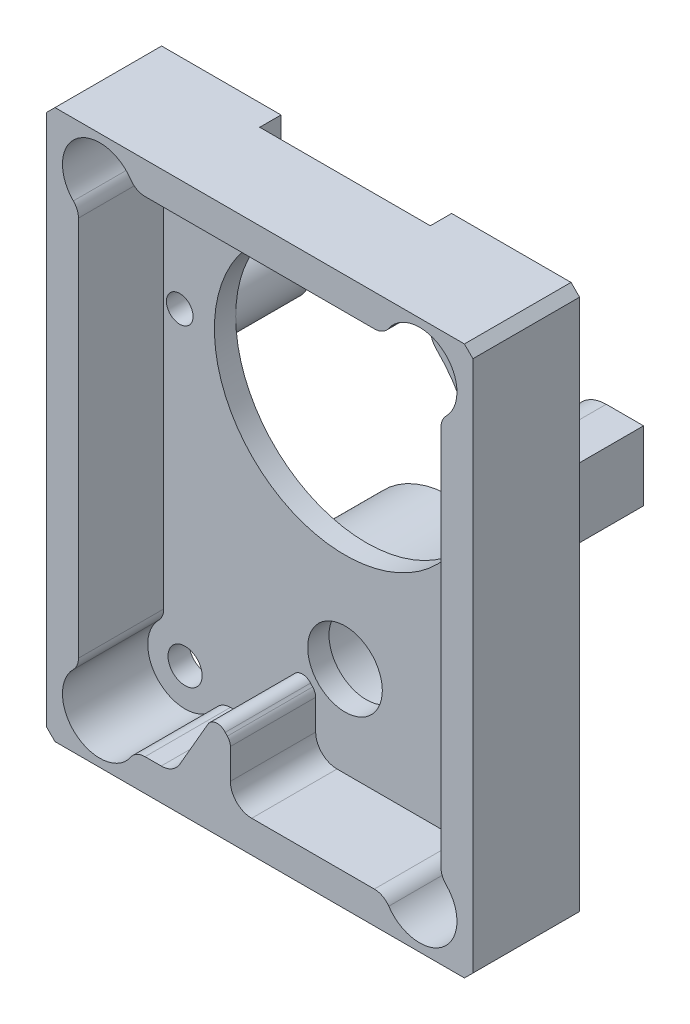
from build123d import *

# Parameters (mm, degrees)
SKETCH1_W             = 40
SKETCH1_H             = 51.5
BOSS_EXTRUDE1_DEPTH   = 18
SKETCH3_R             = 1.6
CUT_EXTRUDE1_DEPTH    = 19
SKETCH4_R             = 3.5
CUT_EXTRUDE2_DEPTH    = 18
CUT_EXTRUDE3_DEPTH    = 8
SKETCH6_R             = 9
CUT_EXTRUDE4_DEPTH    = 8
SKETCH7_R             = 7
CUT_EXTRUDE5_DEPTH    = 2.8
SKETCH8_R             = 6
CUT_EXTRUDE6_DEPTH    = 3.8
SKETCH9_R             = 5
CUT_EXTRUDE7_DEPTH    = 8
M3X0_5_TAPPED_HOLE1_D = 2.5
CUT_EXTRUDE8_DEPTH    = 2
CUT_EXTRUDE9_DEPTH    = 1
CHAMFER1_SIZE         = 0.8
SKETCH14_W            = 1
SKETCH14_H            = 6.5
CUT_EXTRUDE10_DEPTH   = 7


with BuildPart() as part:
    # Sketch1 → Boss-Extrude1 (new body)
    with BuildSketch(Plane.XY):
        Rectangle(SKETCH1_W, SKETCH1_H)
    extrude(amount=BOSS_EXTRUDE1_DEPTH)

    # Sketch3 → Cut-Extrude1 (cut, through all)
    with BuildSketch(Plane.XY.offset(18)):
        with Locations((-15, 21.5)):
            Circle(SKETCH3_R)
        with Locations((-15, -21.5)):
            Circle(SKETCH3_R)
        with Locations((15, 21.5)):
            Circle(SKETCH3_R)
        with Locations((15, -21.5)):
            Circle(SKETCH3_R)
    extrude(amount=-CUT_EXTRUDE1_DEPTH, mode=Mode.SUBTRACT)

    # Sketch4 → Cut-Extrude2 (cut)
    with BuildSketch(Plane.XY.offset(18)):
        with Locations((0, -14.25)):
            Circle(SKETCH4_R)
    extrude(amount=-CUT_EXTRUDE2_DEPTH, mode=Mode.SUBTRACT)

    # Sketch5 → Cut-Extrude3 (cut)
    with BuildSketch(Plane.XY.offset(18)):
        with BuildLine():
            Line((-17, 17.872848693), (-17, -17.872848693))
            ThreePointArc((-17, -17.872848693), (-17.124132538, -18.49783351), (-17.477686074, -19.027941805))
            ThreePointArc((-17.477686074, -19.027941805), (-17.229095042, -24.198357888), (-12.104699799, -23.466529111))
            ThreePointArc((-12.104699799, -23.466529111), (-11.517289712, -22.940191537), (-10.751842764, -22.75))
            Line((-10.751842764, -22.75), (-9.2376, -22.75))
            ThreePointArc((-9.2376, -22.75), (-8.237593216, -22.482046891), (-7.50554136, -21.749986433))
            Line((-7.50554136, -21.749986433), (-4.85642932, -17.161506784))
            ThreePointArc((-4.85642932, -17.161506784), (-4.082002001, -16.665704301), (-3.230119897, -17.011904614))
            ThreePointArc((-3.230119897, -17.011904614), (-3.134851007, -17.11961684), (-3.035950666, -17.224004614))
            ThreePointArc((-3.035950666, -17.224004614), (-2.824243732, -17.545979208), (-2.75, -17.9241))
            Line((-2.75, -17.9241), (-2.75, -20.75))
            ThreePointArc((-2.75, -20.75), (-2.164213562, -22.164213562), (-0.75, -22.75))
            Line((-0.75, -22.75), (10.751842764, -22.75))
            ThreePointArc((10.751842764, -22.75), (11.517289712, -22.940191537), (12.104699799, -23.466529111))
            ThreePointArc((12.104699799, -23.466529111), (17.229095042, -24.198357888), (17.477686074, -19.027941805))
            ThreePointArc((17.477686074, -19.027941805), (17.124132538, -18.49783351), (17, -17.872848693))
            Line((17, -17.872848693), (17, 17.872848693))
            ThreePointArc((17, 17.872848693), (17.124132538, 18.49783351), (17.477686074, 19.027941805))
            ThreePointArc((17.477686074, 19.027941805), (17.229095042, 24.198357888), (12.104699799, 23.466529111))
            ThreePointArc((12.104699799, 23.466529111), (11.517289712, 22.940191537), (10.751842764, 22.75))
            Line((10.751842764, 22.75), (-10.751842764, 22.75))
            ThreePointArc((-10.751842764, 22.75), (-11.517289712, 22.940191537), (-12.104699799, 23.466529111))
            ThreePointArc((-12.104699799, 23.466529111), (-17.229095042, 24.198357888), (-17.477686074, 19.027941805))
            ThreePointArc((-17.477686074, 19.027941805), (-17.124132538, 18.49783351), (-17, 17.872848693))
        make_face()
    extrude(amount=-CUT_EXTRUDE3_DEPTH, mode=Mode.SUBTRACT)

    # Sketch6 → Cut-Extrude4 (cut)
    with BuildSketch(Plane(origin=(0, 0, 0), x_dir=(-1, 0, 0), z_dir=(0, 0, -1))):
        with BuildLine():
            Line((-20, 10.5), (-15.5, 10.5))
            ThreePointArc((-15.5, 10.5), (-12.25, 7.25), (-15.5, 4))
            Line((-15.5, 4), (-20, 4))
            Line((-20, 4), (-20, -25.75))
            Line((-20, -25.75), (20, -25.75))
            Line((20, -25.75), (20, 4))
            Line((20, 4), (15.5, 4))
            ThreePointArc((15.5, 4), (12.25, 7.25), (15.5, 10.5))
            Line((15.5, 10.5), (20, 10.5))
            Line((20, 10.5), (20, 25.75))
            Line((20, 25.75), (-20, 25.75))
            Line((-20, 25.75), (-20, 10.5))
        make_face()
        with Locations((0, -14.25)):
            Circle(SKETCH6_R, mode=Mode.SUBTRACT)
    extrude(amount=-CUT_EXTRUDE4_DEPTH, mode=Mode.SUBTRACT)

    # Sketch7 → Cut-Extrude5 (cut)
    with BuildSketch(Plane(origin=(0, 0, 0), x_dir=(-1, 0, 0), z_dir=(0, 0, -1))):
        with Locations((0, -14.25)):
            Circle(SKETCH7_R)
    extrude(amount=-CUT_EXTRUDE5_DEPTH, mode=Mode.SUBTRACT)

    # Sketch8 → Cut-Extrude6 (cut)
    with BuildSketch(Plane(origin=(0, 0, 0), x_dir=(-1, 0, 0), z_dir=(0, 0, -1))):
        with Locations((0, -14.25)):
            Circle(SKETCH8_R)
    extrude(amount=-CUT_EXTRUDE6_DEPTH, mode=Mode.SUBTRACT)

    # Sketch9 → Cut-Extrude7 (cut)
    with BuildSketch(Plane(origin=(0, 0, 0), x_dir=(-1, 0, 0), z_dir=(0, 0, -1))):
        with Locations((0, -14.25)):
            Circle(SKETCH9_R)
    extrude(amount=-CUT_EXTRUDE7_DEPTH, mode=Mode.SUBTRACT)

    # M3x0.5 Tapped Hole1 (through all)
    with Locations(Plane(origin=(0, 0, 0), x_dir=(-1, 0, 0), z_dir=(0, 0, -1))):
        with Locations((-15.5, 7.25), (15.5, 7.25)):
            Hole(M3X0_5_TAPPED_HOLE1_D / 2)

    # Sketch12 → Cut-Extrude8 (cut)
    with BuildSketch(Plane(origin=(0, 0, 8), x_dir=(-1, 0, 0), z_dir=(0, 0, -1))):
        with BuildLine():
            Line((-8, 17.401970252), (-8, 25.75))
            Line((-8, 25.75), (8, 25.75))
            Line((8, 25.75), (8, 17.401970252))
            ThreePointArc((8, 17.401970252), (8.155139905, 16.629641806), (8.596491228, 15.977132322))
            ThreePointArc((8.596491228, 15.977132322), (0, -5), (-8.596491228, 15.977132322))
            ThreePointArc((-8.596491228, 15.977132322), (-8.155139905, 16.629641806), (-8, 17.401970252))
        make_face()
    extrude(amount=-CUT_EXTRUDE8_DEPTH, mode=Mode.SUBTRACT)

    # Sketch13 → Cut-Extrude9 (cut)
    with BuildSketch(Plane(origin=(0, 0, 0), x_dir=(-1, 0, 0), z_dir=(0, 0, -1))):
        with BuildLine():
            Line((-20, 10.5), (-20, 4))
            Line((-20, 4), (-15.5, 4))
            ThreePointArc((-15.5, 4), (-12.25, 7.25), (-15.5, 10.5))
            Line((-15.5, 10.5), (-20, 10.5))
        make_face()
        with BuildLine():
            Line((20, 4), (20, 10.5))
            Line((20, 10.5), (15.5, 10.5))
            ThreePointArc((15.5, 10.5), (12.25, 7.25), (15.5, 4))
            Line((15.5, 4), (20, 4))
        make_face()
    extrude(amount=-CUT_EXTRUDE9_DEPTH, mode=Mode.SUBTRACT)

    # Chamfer1
    chamfer1_edges = [part.edges().sort_by_distance(p)[0] for p in [
        (20, -25.75, 13),
        (-20, -25.75, 13),
        (-20, 25.75, 13),
        (20, 25.75, 13),
    ]]
    chamfer(chamfer1_edges, length=CHAMFER1_SIZE)

    # Sketch14 → Cut-Extrude10 (cut)
    with BuildSketch(Plane(origin=(0, 0, 1), x_dir=(-1, 0, 0), z_dir=(0, 0, -1))):
        with Locations((-19.5, 7.25)):
            Rectangle(SKETCH14_W, SKETCH14_H)
        with Locations((19.5, 7.25)):
            Rectangle(SKETCH14_W, SKETCH14_H)
    extrude(amount=-CUT_EXTRUDE10_DEPTH, mode=Mode.SUBTRACT)


solid = part.part
